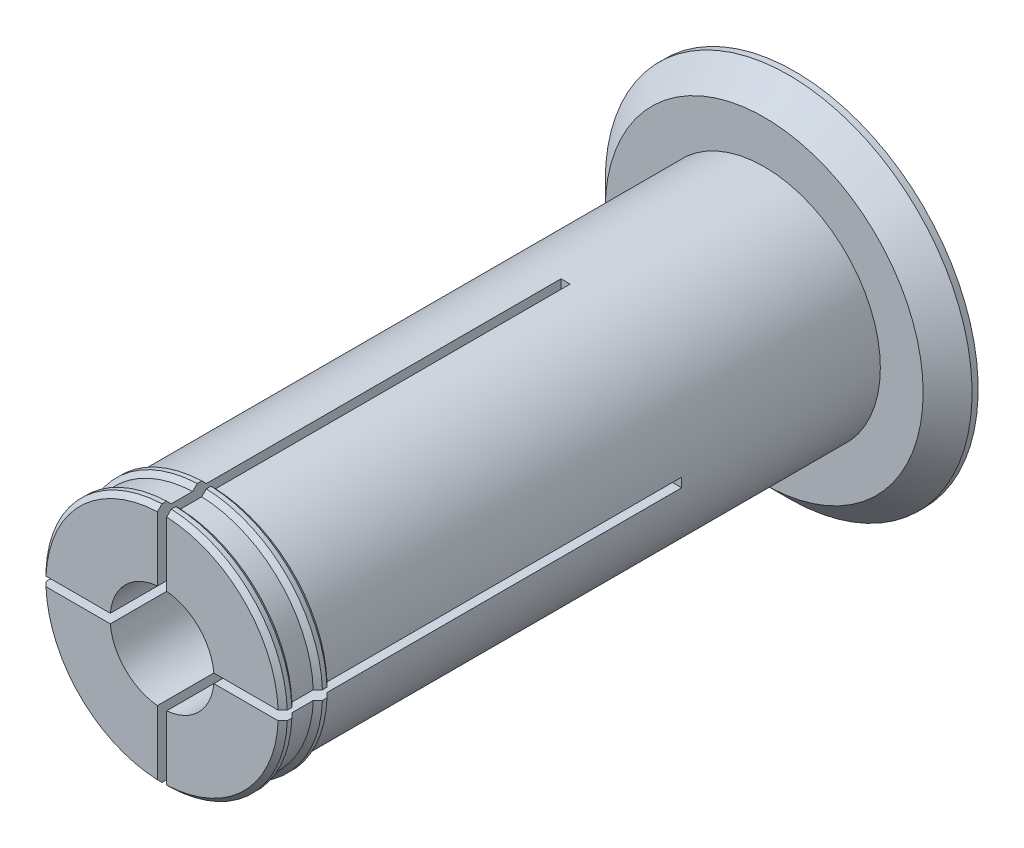
from build123d import *

# Parameters (mm, degrees)
AXLE_BASE_SKETCH_R        = 19
AXLE_DEPTH                = 98.5
GUARD_BASE_R              = 30
GUARD_DEPTH               = 5
INNER_AXLE_HOLE_BASE_R    = 8.5
INNER_AXLE_HOLE_DEPTH     = 104.5
BEND_ROOM_BASE_W          = 1.5
BEND_ROOM_BASE_H          = 50
BEND_ROOM_1_DEPTH         = 66
BEND_ROOM_2_COUNT         = 2
BEND_ROOM_2_ANGLE         = 90
EASY_REMOVAL_CHAMFER_SIZE = 4


with BuildPart() as part:
    # Axle base sketch → Axle (new body)
    with BuildSketch(Plane.XY):
        Circle(AXLE_BASE_SKETCH_R)
    extrude(amount=AXLE_DEPTH)

    # Guard base → Guard (add)
    with BuildSketch(Plane(origin=(0, 0, 0), x_dir=(-1, 0, 0), z_dir=(0, 0, -1))):
        Circle(GUARD_BASE_R)
    extrude(amount=GUARD_DEPTH)

    # Inner axle hole base → Inner axle hole (cut, through all)
    with BuildSketch(Plane.XY.offset(98.5)):
        Circle(INNER_AXLE_HOLE_BASE_R)
    extrude(amount=-INNER_AXLE_HOLE_DEPTH, mode=Mode.SUBTRACT)

    # Mate ring base → Mate rings (revolve)
    with BuildSketch(Plane(origin=(0, 0, 0), x_dir=(1, 0, 0), z_dir=(0, 1, 0))):
        Polygon((19, -98.5), (19.75, -97.75), (19.75, -97), (19, -96.25), align=None)
        Polygon((19, -92.75), (19.75, -92), (19.75, -91.25), (19, -90.5), align=None)
    revolve(axis=Axis((0, 0, 0), (0, 0, -1)))

    # Bend room base → Bend room 1 (cut)
    with BuildSketch(Plane.XY.offset(98.5)):
        Rectangle(BEND_ROOM_BASE_W, BEND_ROOM_BASE_H)
    bend_room_1 = extrude(amount=-BEND_ROOM_1_DEPTH, mode=Mode.SUBTRACT)

    # Bend room 2: Bend room 1 ×2 about axis
    bend_room_2_axis = Axis((0, 0, 0), (0, 0, -1))
    for i in range(1, BEND_ROOM_2_COUNT):
        add(bend_room_1.rotate(bend_room_2_axis, i * BEND_ROOM_2_ANGLE / (BEND_ROOM_2_COUNT - 1)), mode=Mode.SUBTRACT)

    # Easy removal chamfer
    easy_removal_chamfer_edges = [part.edges().sort_by_distance(p)[0] for p in [
        (30, 0, 0),
    ]]
    chamfer(easy_removal_chamfer_edges, length=EASY_REMOVAL_CHAMFER_SIZE)


solid = part.part
